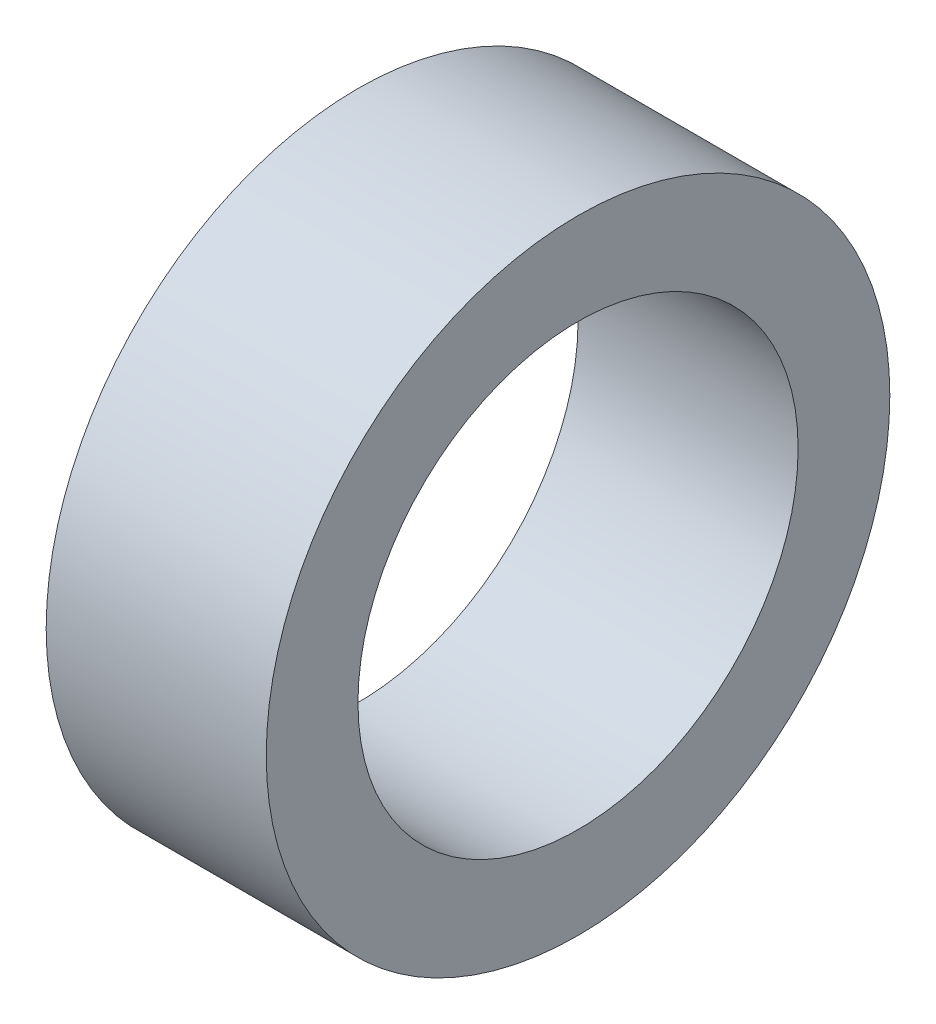
from build123d import *

# Parameters (mm, degrees)
SKETCH1_W = 3
SKETCH1_H = 1.25


with BuildPart() as part:
    # Sketch1 → Revolve1 (revolve)
    with BuildSketch(Plane.XY):
        with Locations((1.5, 3.625)):
            Rectangle(SKETCH1_W, SKETCH1_H)
    revolve(axis=Axis((-88.99, 0, 0), (1, 0, 0)))


solid = part.part
